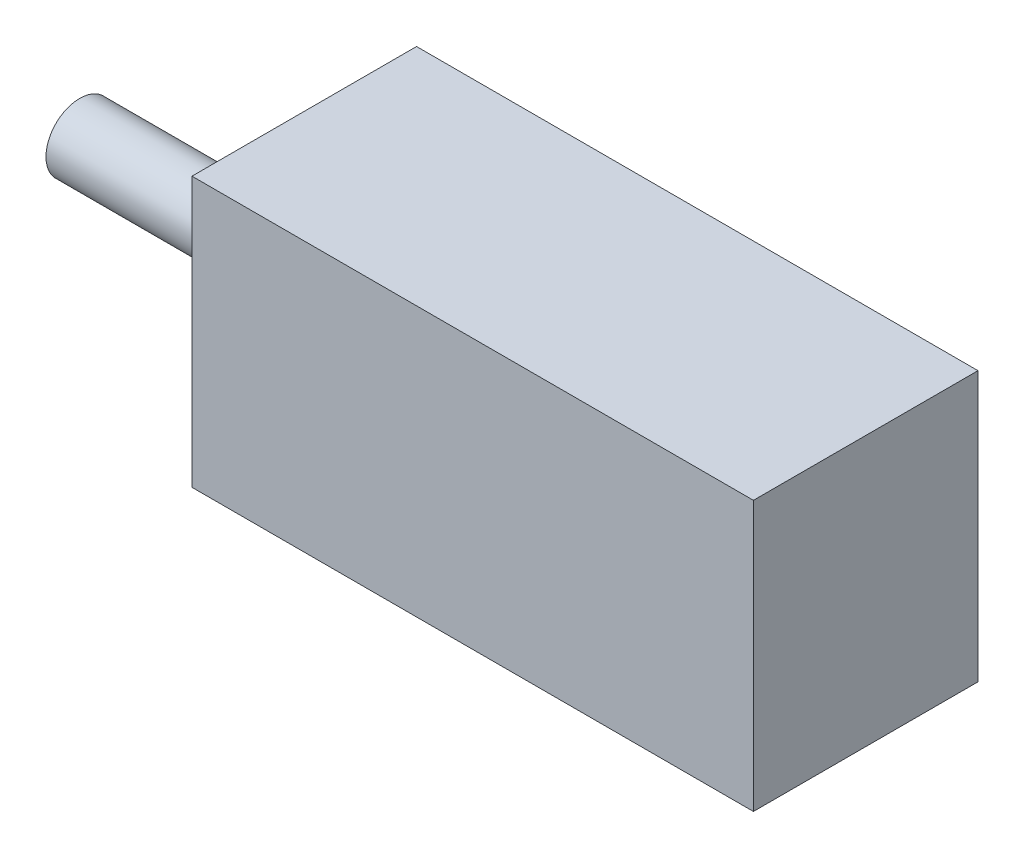
from build123d import *

# Parameters (mm, degrees)
SKETCH1_W           = 25
SKETCH1_H           = 10
BOSS_EXTRUDE1_DEPTH = 12
SKETCH2_R           = 1.5
BOSS_EXTRUDE2_DEPTH = 10


with BuildPart() as part:
    # Sketch1 → Boss-Extrude1 (new body)
    with BuildSketch(Plane(origin=(0, 0, 0), x_dir=(1, 0, 0), z_dir=(0, 1, 0))):
        with Locations((11.19047619, -4.494047619)):
            Rectangle(SKETCH1_W, SKETCH1_H)
    extrude(amount=BOSS_EXTRUDE1_DEPTH)

    # Sketch2 → Boss-Extrude2 (add)
    with BuildSketch(Plane.ZY.offset(1.30952381)):
        with Locations((4.494047619, 6)):
            Circle(SKETCH2_R)
    extrude(amount=BOSS_EXTRUDE2_DEPTH)


solid = part.part
